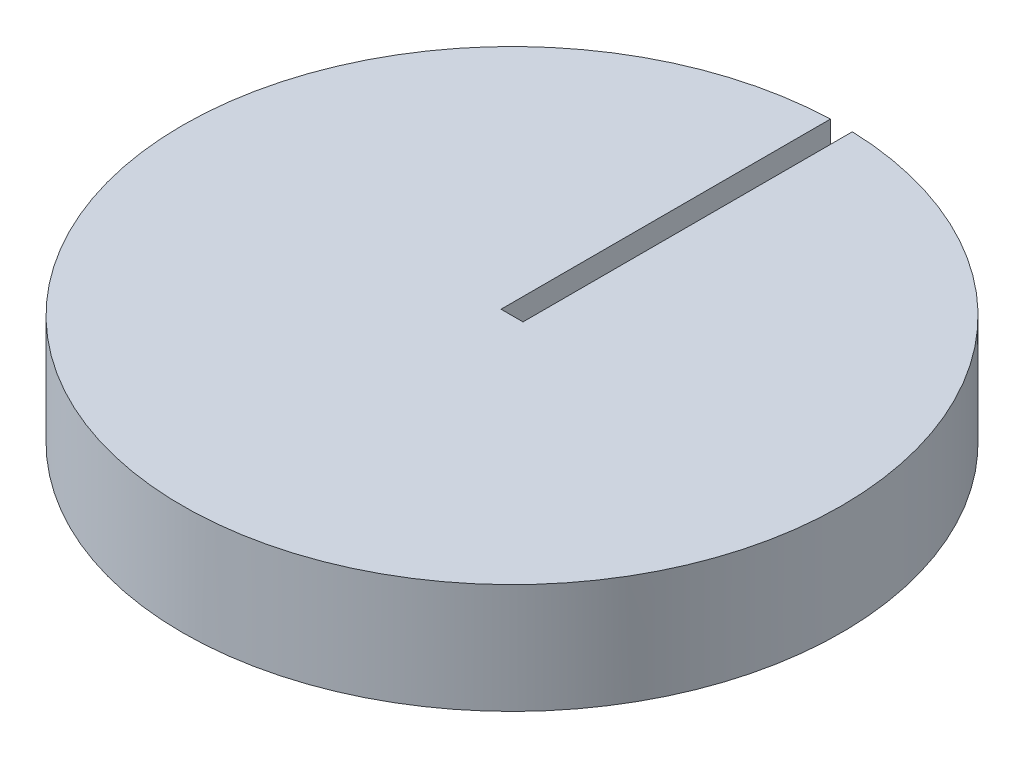
from build123d import *

# Parameters (mm, degrees)
SKETCH1_R               = 38.1
BOSS_EXTRUDE1_DEPTH     = 12.7
SKETCH2_W               = 2.54
SKETCH2_H               = 46.36082965
CUT_EXTRUDE_THIN2_DEPTH = 2.54


with BuildPart() as part:
    # Sketch1 → Boss-Extrude1 (new body)
    with BuildSketch(Plane(origin=(0, 0, 0), x_dir=(1, 0, 0), z_dir=(0, 1, 0))):
        Circle(SKETCH1_R)
    extrude(amount=BOSS_EXTRUDE1_DEPTH)

    # Sketch2 → Cut-Extrude-Thin2 (cut)
    with BuildSketch(Plane(origin=(0, 12.7, 0), x_dir=(1, 0, 0), z_dir=(0, 1, 0))):
        with Locations((0, 23.180414825)):
            Rectangle(SKETCH2_W, SKETCH2_H)
    extrude(amount=-CUT_EXTRUDE_THIN2_DEPTH, mode=Mode.SUBTRACT)


solid = part.part
